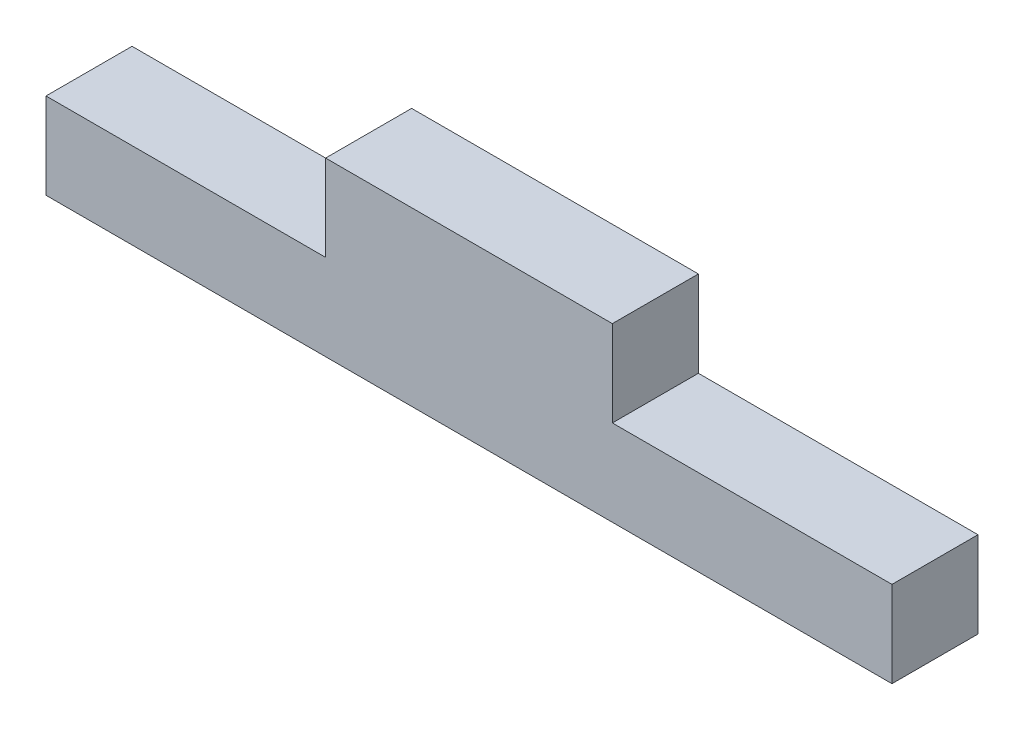
from build123d import *

# Parameters (mm, degrees)
RESSALTO_EXTRUS_O1_DEPTH = 6


with BuildPart() as part:
    # Esboço1 → Ressalto-extrusão1 (new body)
    with BuildSketch(Plane.XY):
        Polygon((19.5, 6), (0, 6), (0, 0), (59, 0), (59, 6), (39.5, 6), (39.5, 12), (19.5, 12), align=None)
    extrude(amount=RESSALTO_EXTRUS_O1_DEPTH)


solid = part.part
